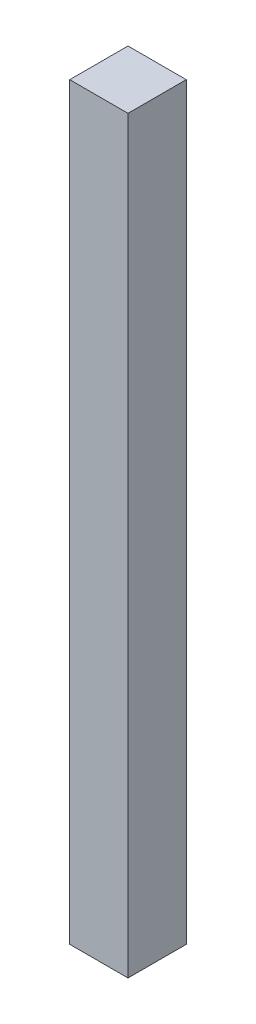
from build123d import *

# Parameters (mm, degrees)
ESQUISSE1_W        = 13
ESQUISSE1_H        = 167
BOSS_EXTRU_1_DEPTH = 13


with BuildPart() as part:
    # Esquisse1 → Boss.-Extru.1 (new body)
    with BuildSketch(Plane.XY):
        with Locations((-67.149945175, 27.958333333)):
            Rectangle(ESQUISSE1_W, ESQUISSE1_H)
    extrude(amount=BOSS_EXTRU_1_DEPTH)


solid = part.part
